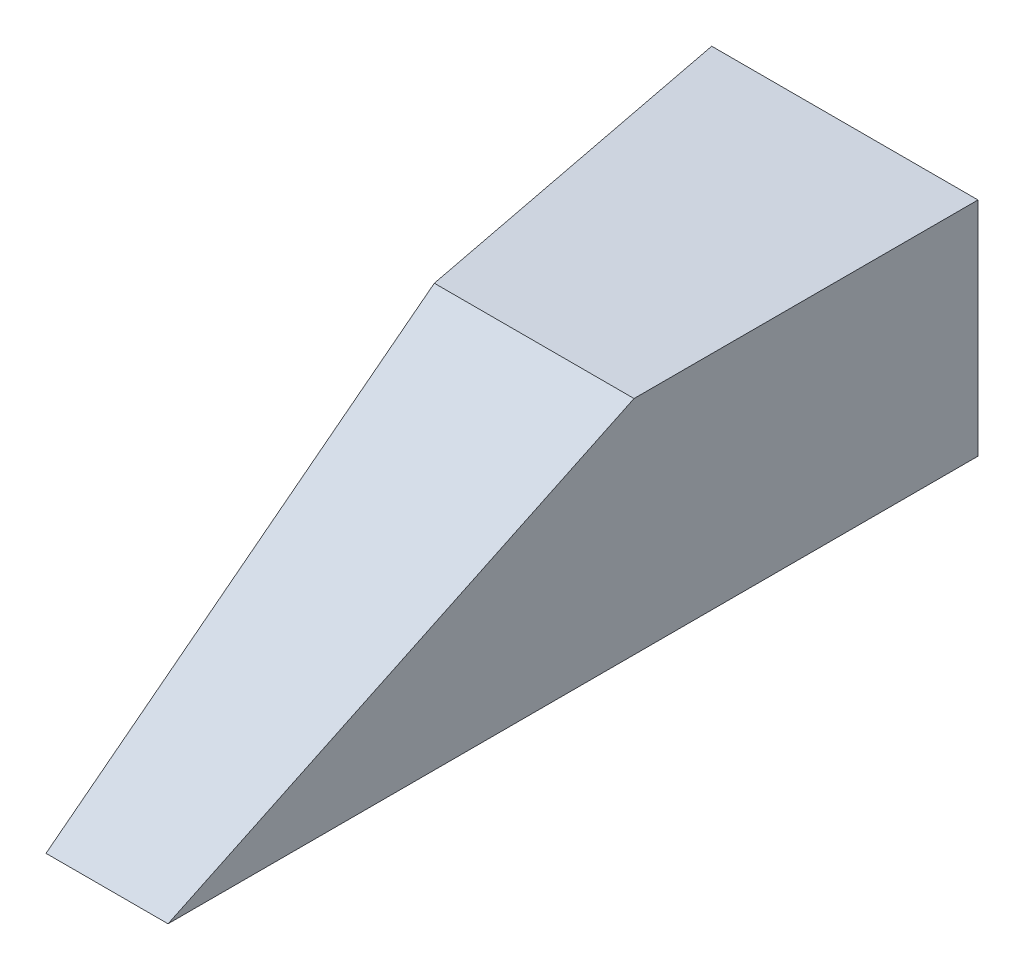
from build123d import *

# Parameters (mm, degrees)
BOSS_EXTRUDE1_DEPTH = 508
CUT_EXTRUDE1_DEPTH  = 508
BOSS_EXTRUDE2_DEPTH = 508
SKETCH4_W           = 1308.893904866
SKETCH4_H           = 2214.808655257
CUT_EXTRUDE2_DEPTH  = 509


with BuildPart() as part:
    # Sketch1 → Boss-Extrude1 (new body)
    with BuildSketch(Plane(origin=(0, 0, 0), x_dir=(1, 0, 0), z_dir=(0, 1, 0))):
        Polygon((0, 1066.8), (0, 0), (279.4, 0), (457.2, 1066.8), align=None)
    boss_extrude1 = extrude(amount=BOSS_EXTRUDE1_DEPTH)

    # Sketch2 → Cut-Extrude1 (cut)
    with BuildSketch(Plane.ZY):
        Polygon((0, 0), (-1066.8, 508), (-1066.8, 732.672417782), (0, 732.672417782), align=None)
    cut_extrude1 = extrude(amount=-CUT_EXTRUDE1_DEPTH, mode=Mode.SUBTRACT)

    # Sketch3 → Boss-Extrude2 (add)
    with BuildSketch(Plane.XZ):
        Polygon((0, -1066.8), (0, -1854.2), (609.6, -1854.2), (457.2, -1066.8), align=None)
    boss_extrude2 = extrude(amount=-BOSS_EXTRUDE2_DEPTH)

    # Mirror1: Boss-Extrude1, Cut-Extrude1, Boss-Extrude2 across plane
    add(boss_extrude1.mirror(Plane(origin=(0, 508, -1066.8), x_dir=(0, 0, 1), z_dir=(1, 0, 0))))
    add(cut_extrude1.mirror(Plane(origin=(0, 508, -1066.8), x_dir=(0, 0, 1), z_dir=(1, 0, 0))), mode=Mode.SUBTRACT)
    add(boss_extrude2.mirror(Plane(origin=(0, 508, -1066.8), x_dir=(0, 0, 1), z_dir=(1, 0, 0))))

    # Sketch4 → Cut-Extrude2 (cut, through all)
    with BuildSketch(Plane(origin=(0, 0, 0), x_dir=(1, 0, 0), z_dir=(0, 1, 0))):
        with Locations((654.446952433, 1107.404327629)):
            Rectangle(SKETCH4_W, SKETCH4_H)
    extrude(amount=CUT_EXTRUDE2_DEPTH, mode=Mode.SUBTRACT)


solid = part.part
